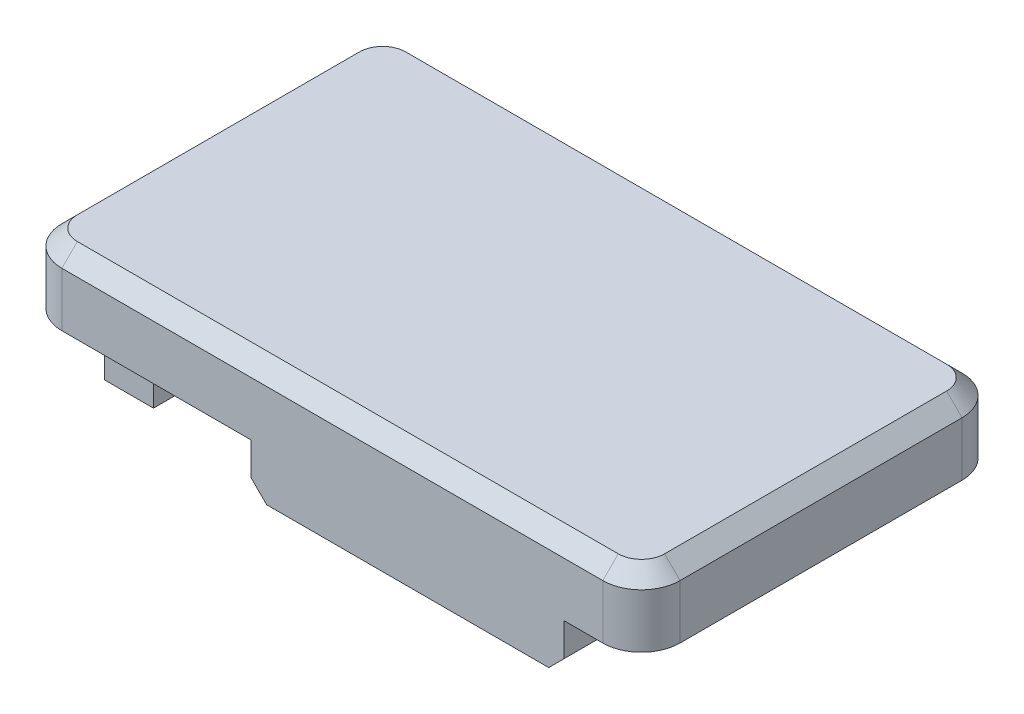
from build123d import *

# Parameters (mm, degrees)
SKETCH_1_W      = 32
SKETCH_1_H      = 18.6
EXTRUDE_1_DEPTH = 3.6
SKETCH_2_W      = 2.54
SKETCH_2_H      = 10.16
EXTRUDE_2_DEPTH = 3.3
SKETCH_3_W      = 16.2
SKETCH_3_H      = 2
EXTRUDE_3_DEPTH = 2.5
FILLET_1_R      = 2
CHAMFER_1_SIZE  = 0.8
CHAMFER_2_SIZE  = 0.8


with BuildPart() as part:
    # 草图1 → 凸台-拉伸1 (new body)
    with BuildSketch(Plane(origin=(0, 0, 0), x_dir=(1, 0, 0), z_dir=(0, 1, 0))):
        with Locations((78.299519248, 9.3)):
            Rectangle(SKETCH_1_W, SKETCH_1_H)
    extrude(amount=EXTRUDE_1_DEPTH)

    # 草图2 → 凸台-拉伸2 (add)
    with BuildSketch(Plane.XZ):
        with Locations((65.569519248, -7.28)):
            Rectangle(SKETCH_2_W, SKETCH_2_H)
    extrude(amount=EXTRUDE_2_DEPTH)

    # 草图3 → 凸台-拉伸3 (add)
    with BuildSketch(Plane.XZ):
        with Locations((82.199519248, -17.6)):
            Rectangle(SKETCH_3_W, SKETCH_3_H)
        with Locations((82.199519248, -1)):
            Rectangle(SKETCH_3_W, SKETCH_3_H)
    extrude(amount=EXTRUDE_3_DEPTH)

    # 圆角1
    fillet_1_edges = [part.edges().sort_by_distance(p)[0] for p in [
        (62.299519248, 1.8, -18.6),
        (94.299519248, 1.8, -18.6),
        (94.299519248, 1.8, 0),
        (62.299519248, 1.8, 0),
    ]]
    fillet(fillet_1_edges, radius=FILLET_1_R)

    # 倒角1
    chamfer_1_edges = [part.edges().sort_by_distance(p)[0] for p in [
        (62.299519248, 3.6, -9.3),
        (78.299519248, 3.6, -18.6),
        (78.299519248, 3.6, 0),
        (94.299519248, 3.6, -9.3),
        (62.885305686, 3.6, -0.585786438),
        (93.71373281, 3.6, -0.585786438),
        (93.71373281, 3.6, -18.014213562),
        (62.885305686, 3.6, -18.014213562),
    ]]
    chamfer(chamfer_1_edges, length=CHAMFER_1_SIZE)

    # 倒角2
    chamfer_2_edges = [part.edges().sort_by_distance(p)[0] for p in [
        (90.299519248, -2.5, -17.6),
        (82.199519248, -2.5, -16.6),
        (74.099519248, -2.5, -17.6),
        (82.199519248, -2.5, -2),
        (90.299519248, -2.5, -1),
        (74.099519248, -2.5, -1),
    ]]
    chamfer(chamfer_2_edges, length=CHAMFER_2_SIZE)


solid = part.part
